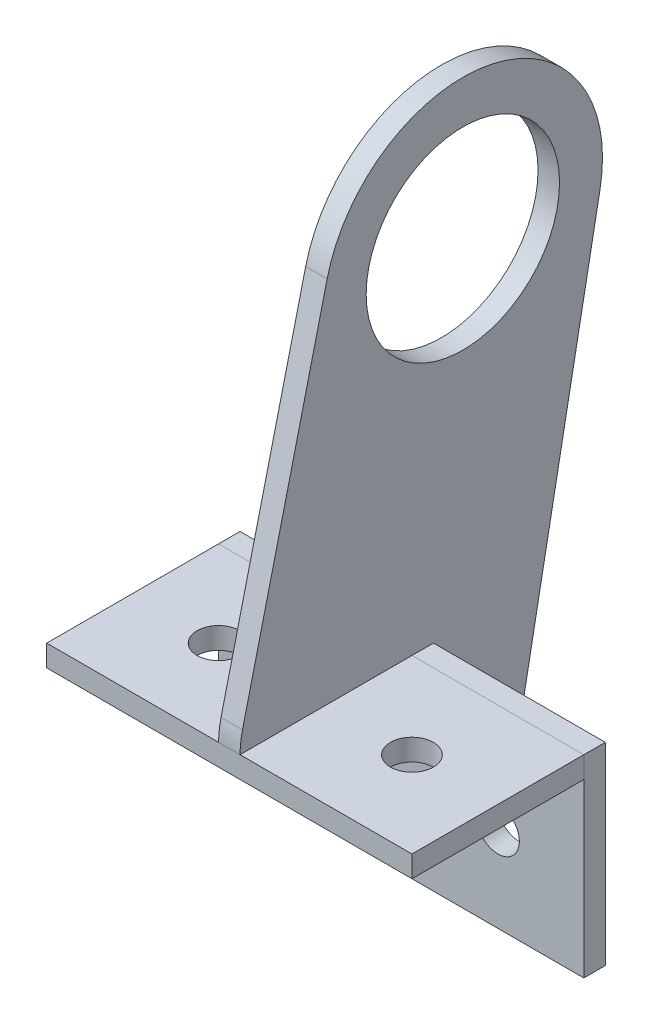
from build123d import *

# Parameters (mm, degrees)
SKETCH1_R           = 14.2875
BOSS_EXTRUDE1_DEPTH = 1.5875
SKETCH2_W           = 53.975
SKETCH2_H           = 28.575
SKETCH2_R           = 3.175
BOSS_EXTRUDE2_DEPTH = 3.175
SKETCH3_W           = 53.975
SKETCH3_H           = 3.175
BOSS_EXTRUDE3_DEPTH = 25.4
SKETCH4_R           = 3.175
CUT_EXTRUDE1_DEPTH  = 29.575


with BuildPart() as part:
    # Sketch1 → Boss-Extrude1 (new body, symmetric)
    with BuildSketch(Plane(origin=(0, 0, 0), x_dir=(0, 0, -1), z_dir=(1, 0, 0))):
        with BuildLine():
            Line((20.275408842, -3.848922256), (8.127174672, -67.843567542))
            ThreePointArc((8.127174672, -67.843567542), (3.74966642, -75.256891632), (-4.35, -78.175))
            Line((-4.35, -78.175), (-4.35, -49.6))
            Line((-4.35, -49.6), (-32.925, -49.6))
            ThreePointArc((-32.925, -49.6), (-32.834845882, -48.08944155), (-32.565663491, -46.600329252))
            Line((-32.565663491, -46.600329252), (-20.053578173, 4.874464966))
            ThreePointArc((-20.053578173, 4.874464966), (4.363103639, 20.171012193), (20.275408842, -3.848922256))
        make_face()
        Circle(SKETCH1_R, mode=Mode.SUBTRACT)
    extrude(amount=BOSS_EXTRUDE1_DEPTH, both=True)


with BuildPart() as body_2:
    # Sketch2 → Boss-Extrude2 (new body)
    with BuildSketch(Plane.XY.offset(4.35)):
        with Locations((0, -63.8875)):
            Rectangle(SKETCH2_W, SKETCH2_H)
        with Locations((-14.2875, -65.475)):
            Circle(SKETCH2_R, mode=Mode.SUBTRACT)
        with Locations((14.2875, -65.475)):
            Circle(SKETCH2_R, mode=Mode.SUBTRACT)
    extrude(amount=BOSS_EXTRUDE2_DEPTH)


with BuildPart() as body_3:
    # Sketch3 → Boss-Extrude3 (new body)
    with BuildSketch(Plane.XY.offset(7.525)):
        with Locations((0, -51.1875)):
            Rectangle(SKETCH3_W, SKETCH3_H)
    extrude(amount=BOSS_EXTRUDE3_DEPTH)

    # Sketch4 → Cut-Extrude1 (cut, through all)
    with BuildSketch(Plane(origin=(0, -49.6, 0), x_dir=(1, 0, 0), z_dir=(0, 1, 0))):
        with Locations((-14.2875, -20.225)):
            Circle(SKETCH4_R)
        with Locations((14.2875, -20.225)):
            Circle(SKETCH4_R)
    extrude(amount=-CUT_EXTRUDE1_DEPTH, mode=Mode.SUBTRACT)


solid = Compound([part.part, body_2.part, body_3.part])
